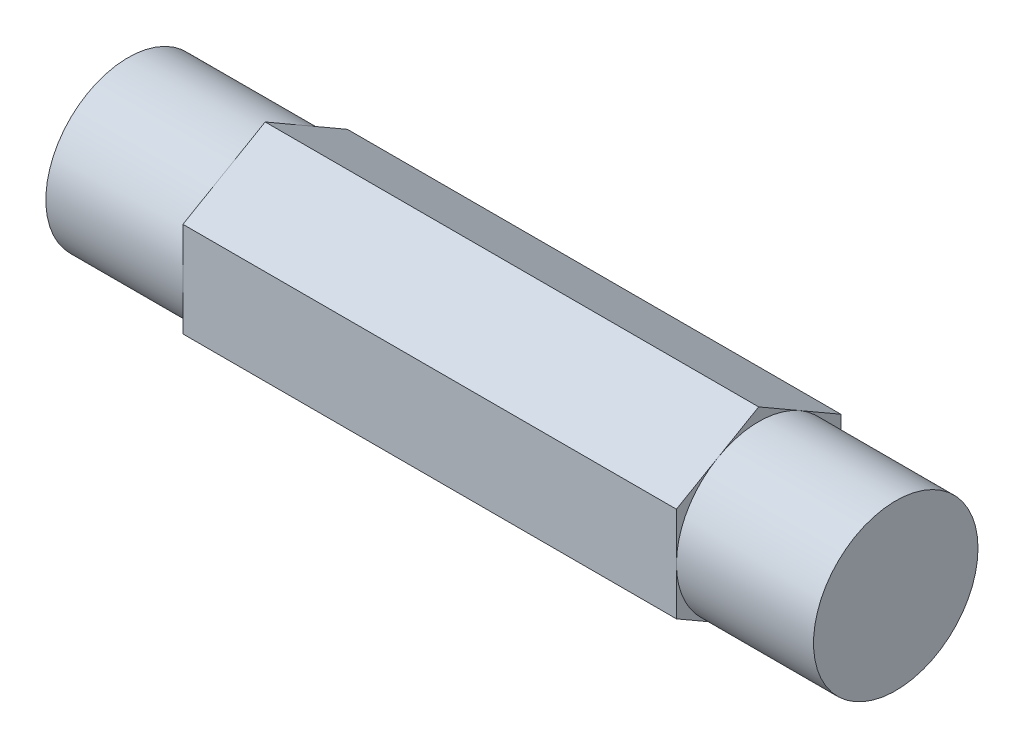
from build123d import *

# Parameters (mm, degrees)
BOSS_EXTRUDE1_DEPTH = 44.45
SKETCH2_R           = 5.499261314
SKETCH2_R_2         = 4.7625
CUT_EXTRUDE1_DEPTH  = 7.9375
SKETCH3_R           = 5.499261314
SKETCH3_R_2         = 4.7625
CUT_EXTRUDE2_DEPTH  = 7.9375


with BuildPart() as part:
    # Sketch1 → Boss-Extrude1 (new body)
    with BuildSketch(Plane(origin=(0, 0, 0), x_dir=(0, 0, -1), z_dir=(1, 0, 0))):
        Polygon((0, 5.499261314), (-4.7625, 2.749630657), (-4.7625, -2.749630657), (0, -5.499261314), (4.7625, -2.749630657), (4.7625, 2.749630657), align=None)
    extrude(amount=BOSS_EXTRUDE1_DEPTH)

    # Sketch2 → Cut-Extrude1 (cut)
    with BuildSketch(Plane.ZY):
        Circle(SKETCH2_R)
        Circle(SKETCH2_R_2, mode=Mode.SUBTRACT)
    extrude(amount=-CUT_EXTRUDE1_DEPTH, mode=Mode.SUBTRACT)

    # Sketch3 → Cut-Extrude2 (cut)
    with BuildSketch(Plane(origin=(44.45, 0, 0), x_dir=(0, 0, -1), z_dir=(1, 0, 0))):
        Circle(SKETCH3_R)
        Circle(SKETCH3_R_2, mode=Mode.SUBTRACT)
    extrude(amount=-CUT_EXTRUDE2_DEPTH, mode=Mode.SUBTRACT)


solid = part.part
